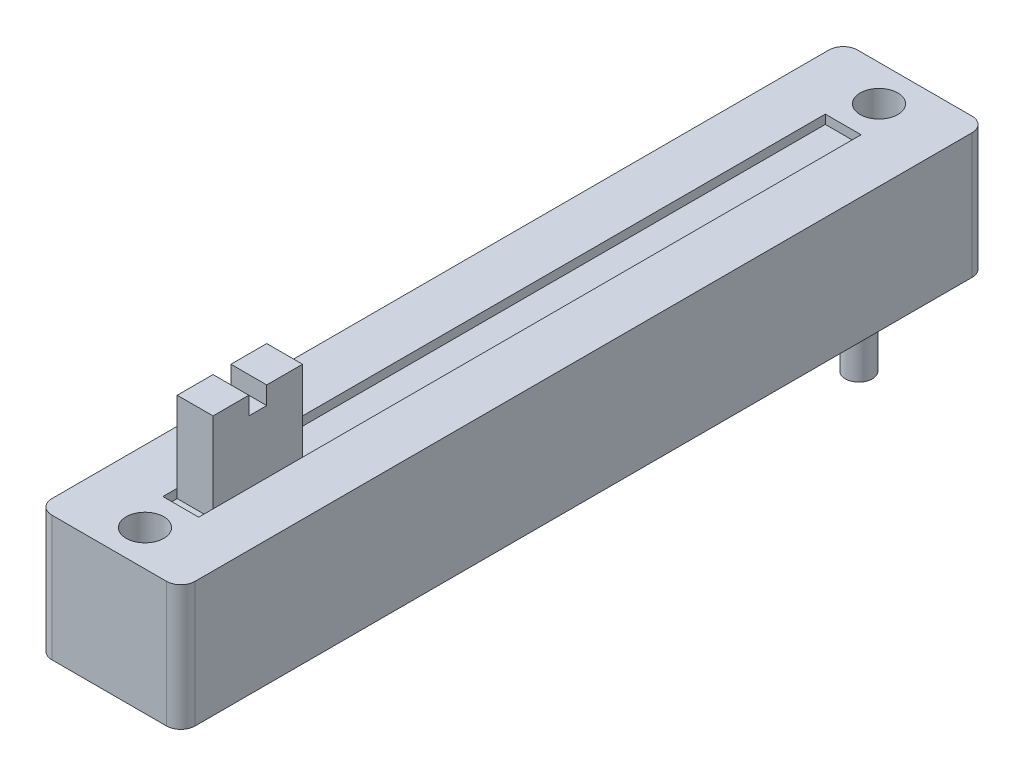
from build123d import *

# Parameters (mm, degrees)
SZKIC1_W                    = 8
SZKIC1_H                    = 45
DODANIE_WYCI_GNI_CIE1_DEPTH = 7
SZKIC2_R                    = 1.05
WYTNIJ_WYCI_GNI_CIE1_DEPTH  = 7
SZKIC3_W                    = 2
SZKIC3_H                    = 37
WYTNIJ_WYCI_GNI_CIE2_DEPTH  = 0.5
SZKIC4_W                    = 2
SZKIC4_H                    = 5
DODANIE_WYCI_GNI_CIE4_DEPTH = 5
SZKIC13_R                   = 0.75
DODANIE_WYCI_GNI_CIE7_DEPTH = 3.5
ZAOKR_GLENIE1_R             = 0.8
SZKIC14_W                   = 2
SZKIC14_H                   = 1
WYTNIJ_WYCI_GNI_CIE3_DEPTH  = 1


with BuildPart() as part:
    # Szkic1 → Dodanie-wyciągnięcie1 (new body)
    with BuildSketch(Plane(origin=(0, 0, 0), x_dir=(1, 0, 0), z_dir=(0, 1, 0))):
        with Locations((4, 22.5)):
            Rectangle(SZKIC1_W, SZKIC1_H)
    extrude(amount=DODANIE_WYCI_GNI_CIE1_DEPTH)

    # Szkic2 → Wytnij-wyciągnięcie1 (cut)
    with BuildSketch(Plane(origin=(0, 7, 0), x_dir=(1, 0, 0), z_dir=(0, 1, 0))):
        with Locations((4, 2)):
            Circle(SZKIC2_R)
        with Locations((4, 43)):
            Circle(SZKIC2_R)
    extrude(amount=-WYTNIJ_WYCI_GNI_CIE1_DEPTH, mode=Mode.SUBTRACT)

    # Szkic3 → Wytnij-wyciągnięcie2 (cut)
    with BuildSketch(Plane(origin=(0, 7, 0), x_dir=(1, 0, 0), z_dir=(0, 1, 0))):
        with Locations((4, 22.5)):
            Rectangle(SZKIC3_W, SZKIC3_H)
    extrude(amount=-WYTNIJ_WYCI_GNI_CIE2_DEPTH, mode=Mode.SUBTRACT)

    # Szkic4 → Dodanie-wyciągnięcie4 (add)
    with BuildSketch(Plane(origin=(0, 6.5, 0), x_dir=(1, 0, 0), z_dir=(0, 1, 0))):
        with Locations((4, 7.3)):
            Rectangle(SZKIC4_W, SZKIC4_H)
    extrude(amount=DODANIE_WYCI_GNI_CIE4_DEPTH)

    # Szkic13 → Dodanie-wyciągnięcie7 (add)
    with BuildSketch(Plane.XZ):
        with Locations((2.125, -40)):
            Circle(SZKIC13_R)
        with Locations((5.875, -40)):
            Circle(SZKIC13_R)
        with Locations((2.125, -5)):
            Circle(SZKIC13_R)
    extrude(amount=DODANIE_WYCI_GNI_CIE7_DEPTH)

    # Zaokrąglenie1
    zaokr_glenie1_edges = [part.edges().sort_by_distance(p)[0] for p in [
        (0, 3.5, -45),
        (8, 3.5, -45),
        (8, 3.5, 0),
        (0, 3.5, 0),
    ]]
    fillet(zaokr_glenie1_edges, radius=ZAOKR_GLENIE1_R)

    # Szkic14 → Wytnij-wyciągnięcie3 (cut)
    with BuildSketch(Plane(origin=(0, 11.5, 0), x_dir=(1, 0, 0), z_dir=(0, 1, 0))):
        with Locations((4, 7.3)):
            Rectangle(SZKIC14_W, SZKIC14_H)
    extrude(amount=-WYTNIJ_WYCI_GNI_CIE3_DEPTH, mode=Mode.SUBTRACT)


solid = part.part
